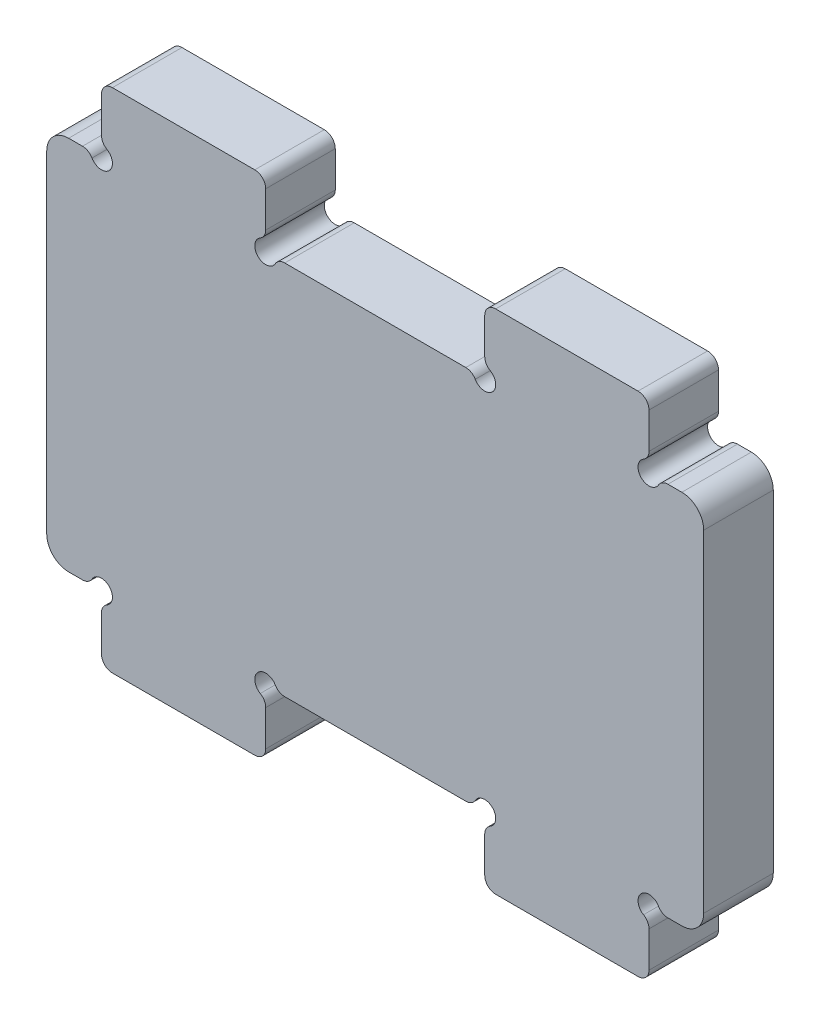
from build123d import *

# Parameters (mm, degrees)
SKETCH1_W               = 60
SKETCH1_H               = 34.3
BOSS_EXTRUDE1_DEPTH     = 6.35
SKETCH2_W               = 15
SKETCH2_H               = 6
BOSS_EXTRUDE2_DEPTH     = 6.35
SKETCH3_R               = 1
CUT_EXTRUDE1_DEPTH      = 7.35
MIRROR2_COPY_1_SKETCH_W = 15
MIRROR2_COPY_1_SKETCH_H = 6
MIRROR2_COPY_1_DEPTH    = 6.35
MIRROR2_COPY_2_SKETCH_R = 1
MIRROR2_COPY_2_DEPTH    = 7.35
FILLET1_R               = 1
FILLET2_R               = 2


with BuildPart() as part:
    # Sketch1 → Boss-Extrude1 (new body)
    with BuildSketch(Plane.XY):
        Rectangle(SKETCH1_W, SKETCH1_H)
    extrude(amount=BOSS_EXTRUDE1_DEPTH)

    # Sketch2 → Boss-Extrude2 (add)
    with BuildSketch(Plane.XY.offset(6.35)):
        with Locations((-17.5, 20.15)):
            Rectangle(SKETCH2_W, SKETCH2_H)
    boss_extrude2 = extrude(amount=-BOSS_EXTRUDE2_DEPTH)

    # Sketch3 → Cut-Extrude1 (cut, through all)
    with BuildSketch(Plane.XY.offset(6.35)):
        with Locations((-25, 17.15)):
            Circle(SKETCH3_R)
        with Locations((-10, 17.15)):
            Circle(SKETCH3_R)
    cut_extrude1 = extrude(amount=-CUT_EXTRUDE1_DEPTH, mode=Mode.SUBTRACT)

    # Mirror1: Boss-Extrude2, Cut-Extrude1 across plane
    add(boss_extrude2.mirror(Plane(origin=(0, 0, 0), x_dir=(0, 0, 1), z_dir=(1, 0, 0))))
    add(cut_extrude1.mirror(Plane(origin=(0, 0, 0), x_dir=(0, 0, 1), z_dir=(1, 0, 0))), mode=Mode.SUBTRACT)

    # Mirror2: Boss-Extrude2, Cut-Extrude1 across plane
    add(boss_extrude2.mirror(Plane.ZX))
    add(cut_extrude1.mirror(Plane.ZX), mode=Mode.SUBTRACT)

    # Mirror2 copy 1 sketch → Mirror2 copy 1 (add)
    with BuildSketch(Plane(origin=(0, 0, 6.35), x_dir=(-1, 0, 0), z_dir=(0, 0, 1))):
        with Locations((-17.5, 20.15)):
            Rectangle(MIRROR2_COPY_1_SKETCH_W, MIRROR2_COPY_1_SKETCH_H)
    extrude(amount=-MIRROR2_COPY_1_DEPTH)

    # Mirror2 copy 2 sketch → Mirror2 copy 2 (cut, through all)
    with BuildSketch(Plane(origin=(0, 0, 6.35), x_dir=(-1, 0, 0), z_dir=(0, 0, 1))):
        with Locations((-25, 17.15)):
            Circle(MIRROR2_COPY_2_SKETCH_R)
        with Locations((-10, 17.15)):
            Circle(MIRROR2_COPY_2_SKETCH_R)
    extrude(amount=-MIRROR2_COPY_2_DEPTH, mode=Mode.SUBTRACT)

    # Fillet1
    fillet1_edges = [part.edges().sort_by_distance(p)[0] for p in [
        (26, -17.15, 3.175),
        (9, -17.15, 3.175),
        (-10, -23.15, 3.175),
        (-25, -23.15, 3.175),
        (-25, -18.15, 3.175),
        (-10, -18.15, 3.175),
        (-26, -17.15, 3.175),
        (-9, -17.15, 3.175),
        (-25, 23.15, 3.175),
        (-10, 23.15, 3.175),
        (-10, 18.15, 3.175),
        (-25, 18.15, 3.175),
        (-26, 17.15, 3.175),
        (-9, 17.15, 3.175),
        (10, 23.15, 3.175),
        (25, 23.15, 3.175),
        (25, 18.15, 3.175),
        (10, 18.15, 3.175),
        (26, 17.15, 3.175),
        (9, 17.15, 3.175),
        (25, -23.15, 3.175),
        (10, -23.15, 3.175),
        (10, -18.15, 3.175),
        (25, -18.15, 3.175),
    ]]
    fillet(fillet1_edges, radius=FILLET1_R)

    # Fillet2
    fillet2_edges = [part.edges().sort_by_distance(p)[0] for p in [
        (-30, 17.15, 3.175),
        (30, 17.15, 3.175),
        (30, -17.15, 3.175),
        (-30, -17.15, 3.175),
    ]]
    fillet(fillet2_edges, radius=FILLET2_R)


solid = part.part
